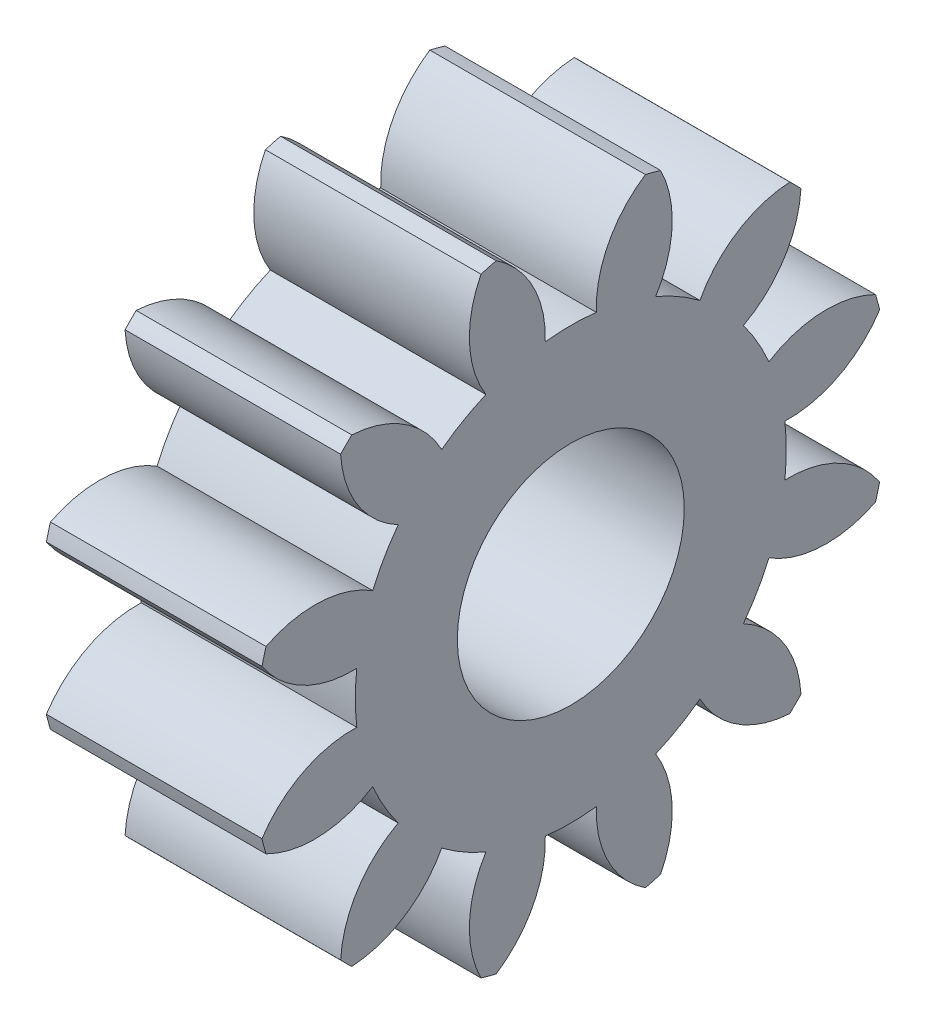
from build123d import *

# Parameters (mm, degrees)
BASPROSKE_W        = 5
BASPROSKE_H        = 7
TOOTHCUT_DEPTH     = 12.090536506
TEETHCUTS_COUNT    = 12
TEETHCUTS_ANGLE    = 330
BORSKE_R           = 2.5
BORE_DEPTH         = 50.0000508
SKETCH1_W          = 20.08971131
SKETCH1_H          = 17.337649252
CUT_EXTRUDE3_DEPTH = 0.25


with BuildPart() as part:
    # BasProSke → Base-Revolve (revolve)
    with BuildSketch(Plane(origin=(0, 0, 0), x_dir=(1, 0, 0), z_dir=(0, 1, 0)), mode=Mode.PRIVATE) as base_revolve_sk:
        with Locations((2.5, 3.5)):
            Rectangle(BASPROSKE_W, BASPROSKE_H)
    revolve(base_revolve_sk.sketch.rotate(Axis((-10, 0, 0), (1, 0, 0)), 180), axis=Axis((-10, 0, 0), (1, 0, 0)))

    # TooCutSke → ToothCut (cut, through all)
    with BuildSketch(Plane(origin=(0, 0, 0), x_dir=(0, 0, -1), z_dir=(1, 0, 0))):
        with BuildLine():
            ThreePointArc((0.562207301, 4.715604304), (0, 4.749), (-0.562207301, 4.715604304))
            ThreePointArc((-0.562207301, 4.715604304), (-0.837528627, 5.917009812), (-1.672850686, 6.823328788))
            ThreePointArc((-1.672850686, 6.823328788), (0, 7.0254), (1.672850686, 6.823328788))
            ThreePointArc((1.672850686, 6.823328788), (0.837528627, 5.917009812), (0.562207301, 4.715604304))
        make_face()
    toothcut = extrude(amount=TOOTHCUT_DEPTH, mode=Mode.SUBTRACT)

    # TeethCuts: ToothCut ×12 about axis
    teethcuts_axis = Axis((-10, 0, 0), (1, 0, 0))
    for i in range(1, TEETHCUTS_COUNT):
        add(toothcut.rotate(teethcuts_axis, i * TEETHCUTS_ANGLE / (TEETHCUTS_COUNT - 1)), mode=Mode.SUBTRACT)

    # BorSke → Bore (cut, symmetric)
    with BuildSketch(Plane(origin=(0, 0, 0), x_dir=(0, 0, -1), z_dir=(1, 0, 0))):
        with Locations(Location((0, 0, 0), (0, 0, 180))):
            Circle(BORSKE_R)
    extrude(amount=BORE_DEPTH, both=True, mode=Mode.SUBTRACT)

    # Sketch1 → Cut-Extrude3 (cut)
    with BuildSketch(Plane(origin=(5, 0, 0), x_dir=(0, 0, -1), z_dir=(1, 0, 0))):
        with Locations((2.500843807, -0.387105296)):
            Rectangle(SKETCH1_W, SKETCH1_H)
    extrude(amount=-CUT_EXTRUDE3_DEPTH, mode=Mode.SUBTRACT)


solid = part.part
